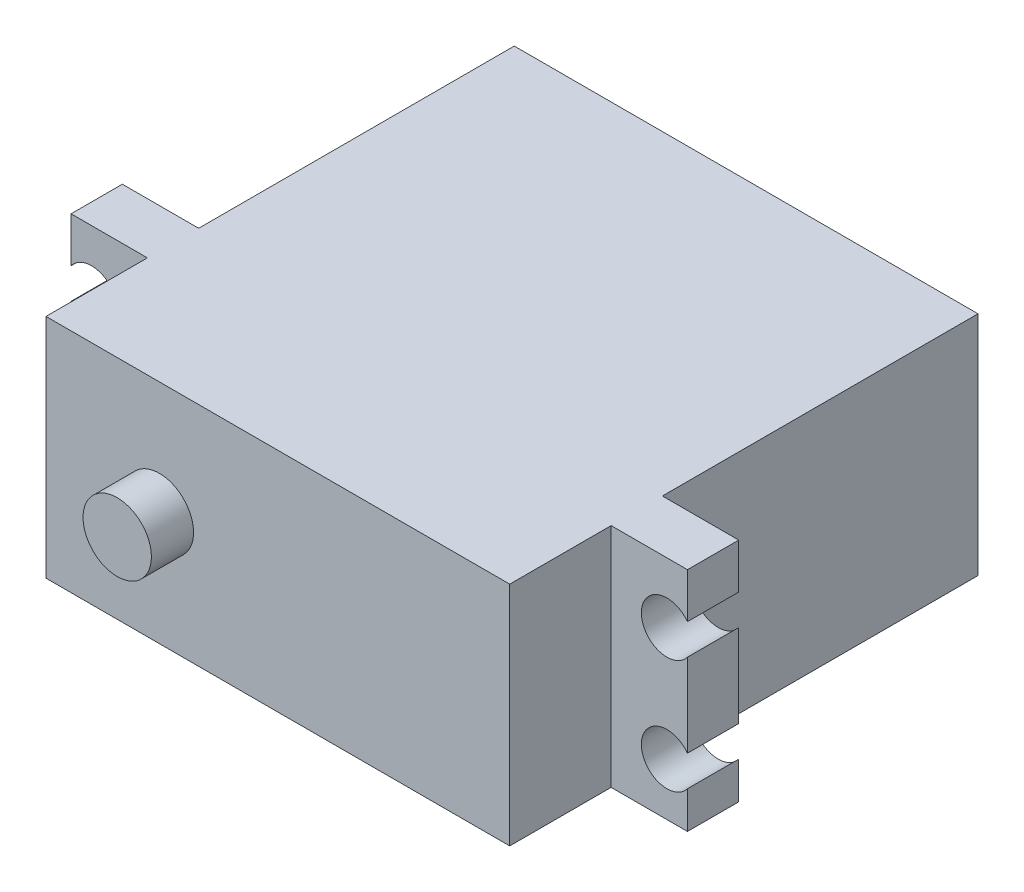
from build123d import *

# Parameters (mm, degrees)
SKETCH1_W           = 40.7
SKETCH1_H           = 19.9
BOSS_EXTRUDE1_DEPTH = 41.1
SKETCH2_W           = 54.1
SKETCH2_H           = 4.5
BOSS_EXTRUDE2_DEPTH = 19.9
CUT_EXTRUDE1_REACH  = 34.2
SKETCH3_R           = 2.25
SKETCH4_R           = 3
BOSS_EXTRUDE3_DEPTH = 3.7
SKETCH6_W           = 4.5
SKETCH6_H           = 6.7
BOSS_EXTRUDE4_DEPTH = 5.5


with BuildPart() as part:
    # Sketch1 → Boss-Extrude1 (new body)
    with BuildSketch(Plane.XY):
        Rectangle(SKETCH1_W, SKETCH1_H)
    extrude(amount=BOSS_EXTRUDE1_DEPTH)

    # Sketch2 → Boss-Extrude2 (add)
    with BuildSketch(Plane.XZ.offset(9.95)):
        with Locations((0, 29.95)):
            Rectangle(SKETCH2_W, SKETCH2_H)
    extrude(amount=-BOSS_EXTRUDE2_DEPTH)

    # Sketch3 → Cut-Extrude1 (cut, up to next)
    with BuildSketch(Plane.XY.offset(32.2), mode=Mode.PRIVATE) as cut_extrude1_sk1:
        with Locations((-25.25, 4.649810013)):
            Circle(SKETCH3_R)
    cut_extrude1_tool1 = extrude(cut_extrude1_sk1.sketch, amount=-CUT_EXTRUDE1_REACH, mode=Mode.PRIVATE) & part.part
    add(cut_extrude1_tool1.solids().sort_by_distance((-25.25, 4.64981, 32.2))[0], mode=Mode.SUBTRACT)
    # Sketch3 → Cut-Extrude1 (cut, up to next)
    with BuildSketch(Plane.XY.offset(32.2), mode=Mode.PRIVATE) as cut_extrude1_sk2:
        with Locations((-25.25, -5.350189987)):
            Circle(SKETCH3_R)
    cut_extrude1_tool2 = extrude(cut_extrude1_sk2.sketch, amount=-CUT_EXTRUDE1_REACH, mode=Mode.PRIVATE) & part.part
    add(cut_extrude1_tool2.solids().sort_by_distance((-25.25, -5.35019, 32.2))[0], mode=Mode.SUBTRACT)
    # Sketch3 → Cut-Extrude1 (cut, up to next)
    with BuildSketch(Plane.XY.offset(32.2), mode=Mode.PRIVATE) as cut_extrude1_sk3:
        with Locations((25.25, 4.649810013)):
            Circle(SKETCH3_R)
    cut_extrude1_tool3 = extrude(cut_extrude1_sk3.sketch, amount=-CUT_EXTRUDE1_REACH, mode=Mode.PRIVATE) & part.part
    add(cut_extrude1_tool3.solids().sort_by_distance((25.25, 4.64981, 32.2))[0], mode=Mode.SUBTRACT)
    # Sketch3 → Cut-Extrude1 (cut, up to next)
    with BuildSketch(Plane.XY.offset(32.2), mode=Mode.PRIVATE) as cut_extrude1_sk4:
        with Locations((25.25, -5.350189987)):
            Circle(SKETCH3_R)
    cut_extrude1_tool4 = extrude(cut_extrude1_sk4.sketch, amount=-CUT_EXTRUDE1_REACH, mode=Mode.PRIVATE) & part.part
    add(cut_extrude1_tool4.solids().sort_by_distance((25.25, -5.35019, 32.2))[0], mode=Mode.SUBTRACT)

    # Sketch4 → Boss-Extrude3 (add)
    with BuildSketch(Plane.XY.offset(41.1)):
        with Locations((-10.4, 0)):
            Circle(SKETCH4_R)
    extrude(amount=BOSS_EXTRUDE3_DEPTH)

    # Sketch6 → Boss-Extrude4 (add)
    with BuildSketch(Plane.ZY.offset(20.35)):
        with Locations((5.75, 0)):
            Rectangle(SKETCH6_W, SKETCH6_H)
    extrude(amount=BOSS_EXTRUDE4_DEPTH)


solid = part.part
